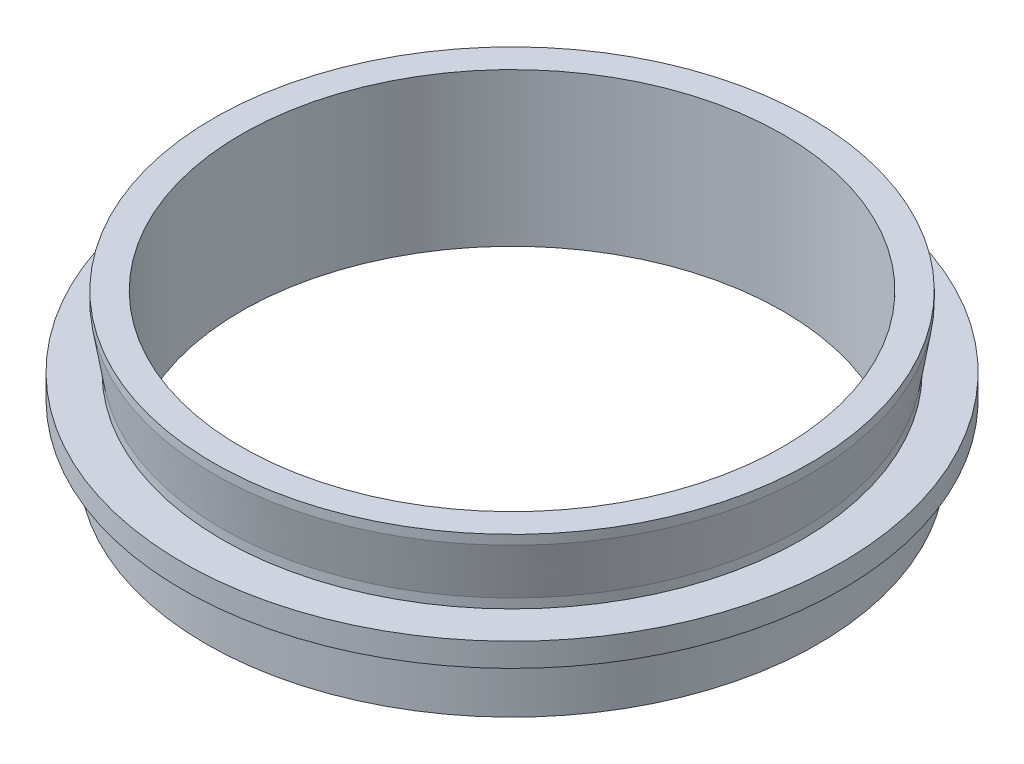
from build123d import *


with BuildPart() as part:
    # 草图1 → 旋转1 (revolve)
    with BuildSketch(Plane.XY, mode=Mode.PRIVATE) as revolve_1_sk:
        Polygon((-23, 0), (-23, 13), (-25.365, 13), (-25.365, 12.2), (-24.635, 7.8), (-24.635, 7), (-28, 7), (-28, 5), (-25.6, 5), (-25.6, 4), (-26, 4), (-26, 0), align=None)
    revolve(revolve_1_sk.sketch.rotate(Axis((0, 0, 0), (0, 1, 0)), 270), axis=Axis((0, 0, 0), (0, 1, 0)))  # turned: the seam where the file's is


solid = part.part
